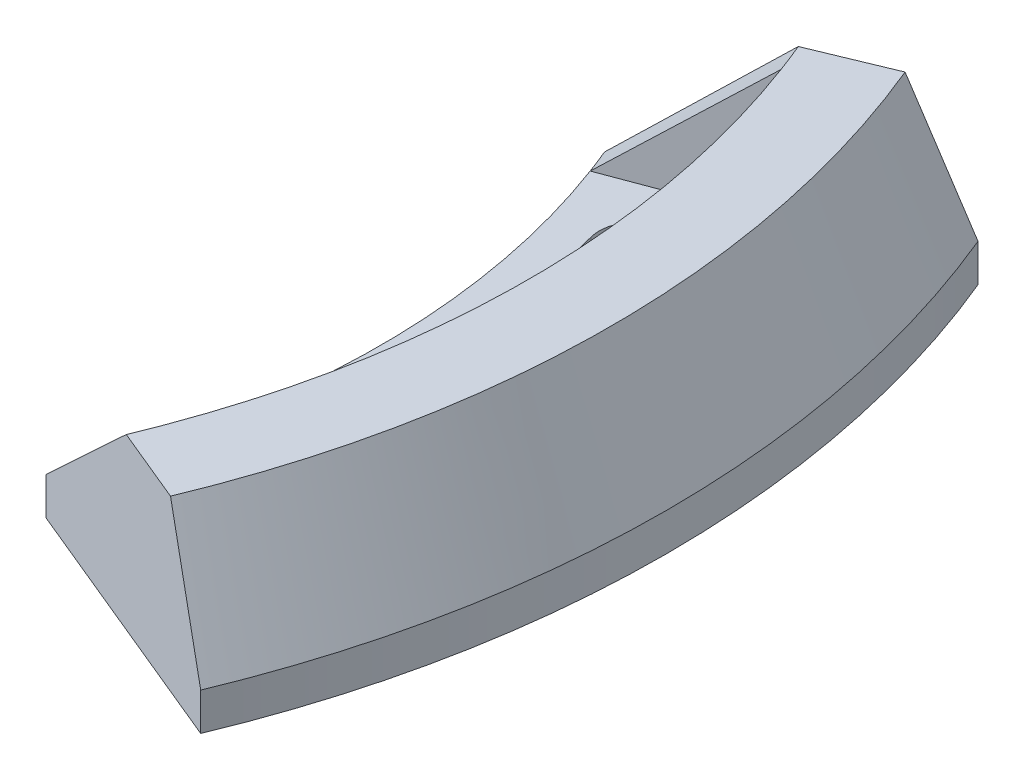
from build123d import *

# Parameters (mm, degrees)
REVOLVE1_ANGLE     = 45
REVOLVE2_ANGLE     = 2
CUT_EXTRUDE1_DEPTH = 6


with BuildPart() as part:
    # Sketch1 → Revolve1 (revolve, symmetric)
    with BuildSketch(Plane.XY) as revolve1_sk:
        Polygon((97, 0), (97, 5), (124.136396226, 5), (116.717495749, 22.477834241), (127.581099523, 22.477834241), (135, 5), (135, 0), align=None)
    revolve(axis=Axis((0, 0, 0), (0, 1, 0)), revolution_arc=REVOLVE1_ANGLE / 2)
    revolve(revolve1_sk.sketch, axis=Axis((0, 0, 0), (0, -1, 0)), revolution_arc=REVOLVE1_ANGLE / 2)

    # Sketch2 → Revolve2 (revolve)
    with BuildSketch(Plane(origin=(0, 0, 0), x_dir=(0.923879533, 0, 0.382683432), z_dir=(-0.382683432, 0, 0.923879533))):
        Polygon((97, 5), (116.717495749, 22.477834241), (124.136396226, 5), align=None)
    revolve2 = revolve(axis=Axis((0, 0, 0), (0, 1, 0)), revolution_arc=REVOLVE2_ANGLE)

    # Mirror1: Revolve2 across plane
    add(revolve2.mirror(Plane.XY))

    # Sketch3 → Cut-Extrude1 (cut, through all)
    with BuildSketch(Plane(origin=(0, 5, 0), x_dir=(1, 0, 0), z_dir=(0, 1, 0))):
        with BuildLine():
            ThreePointArc((108.183692544, -28.987733051), (112, 0), (108.183692544, 28.987733051))
            ThreePointArc((108.183692544, 28.987733051), (102.059968187, 32.523266957), (98.524434281, 26.3995426))
            ThreePointArc((98.524434281, 26.3995426), (102, 0), (98.524434281, -26.3995426))
            ThreePointArc((98.524434281, -26.3995426), (102.059968187, -32.523266957), (108.183692544, -28.987733051))
        make_face()
    extrude(amount=-CUT_EXTRUDE1_DEPTH, mode=Mode.SUBTRACT)


solid = part.part
